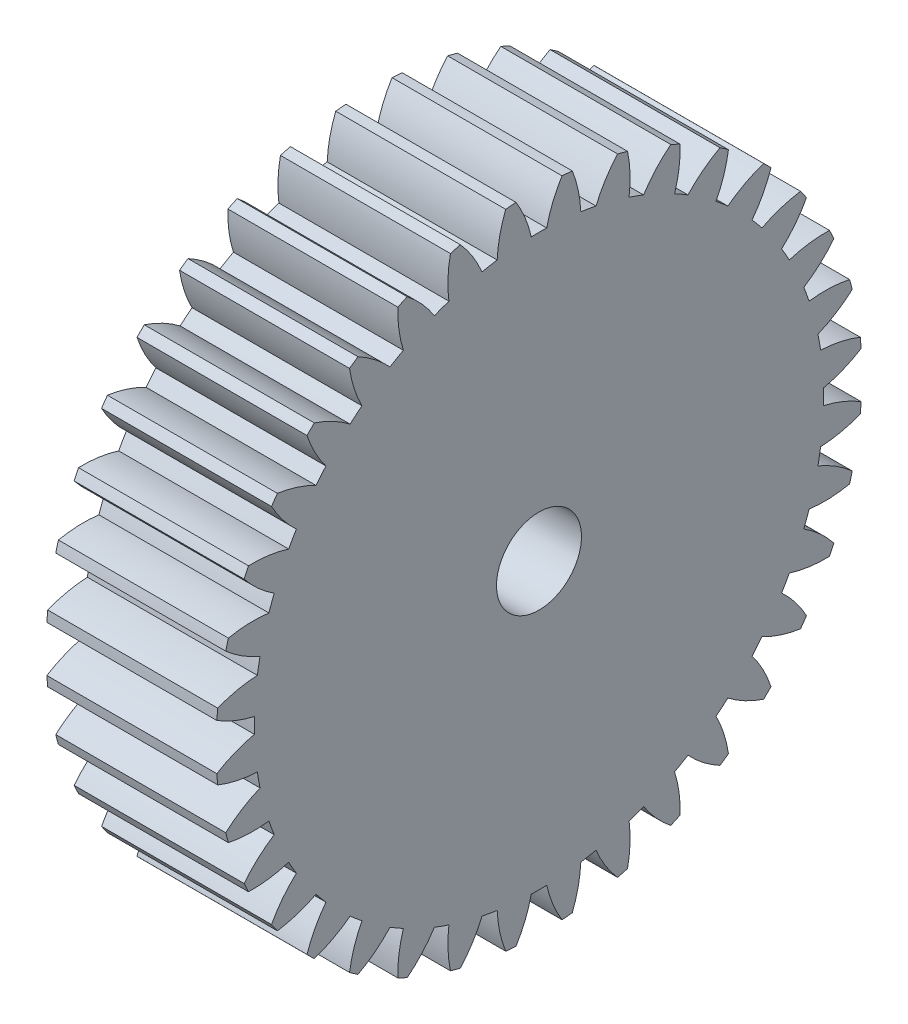
from build123d import *

# Parameters (mm, degrees)
BASPROSKE_W     = 10
BASPROSKE_H     = 19
TOOTHCUT_DEPTH  = 29.670542374
TEETHCUTS_COUNT = 36
TEETHCUTS_ANGLE = 350
BORSKE_R        = 2.5
BORE_DEPTH      = 50.0000508


with BuildPart() as part:
    # BasProSke → Base-Revolve (revolve)
    with BuildSketch(Plane(origin=(0, 0, 0), x_dir=(1, 0, 0), z_dir=(0, 1, 0)), mode=Mode.PRIVATE) as base_revolve_sk:
        with Locations((5, 9.5)):
            Rectangle(BASPROSKE_W, BASPROSKE_H)
    revolve(base_revolve_sk.sketch.rotate(Axis((-10, 0, 0), (1, 0, 0)), 180), axis=Axis((-10, 0, 0), (1, 0, 0)))

    # TooCutSke → ToothCut (cut, through all)
    with BuildSketch(Plane(origin=(0, 0, 0), x_dir=(0, 0, -1), z_dir=(1, 0, 0))):
        with BuildLine():
            ThreePointArc((0.454664826, 16.742827745), (0, 16.749), (-0.454664826, 16.742827745))
            ThreePointArc((-0.454664826, 16.742827745), (-0.817558311, 17.898033097), (-1.368909141, 18.976088452))
            ThreePointArc((-1.368909141, 18.976088452), (0, 19.0254), (1.368909141, 18.976088452))
            ThreePointArc((1.368909141, 18.976088452), (0.817558311, 17.898033097), (0.454664826, 16.742827745))
        make_face()
    toothcut = extrude(amount=TOOTHCUT_DEPTH, mode=Mode.SUBTRACT)

    # TeethCuts: ToothCut ×36 about axis
    teethcuts_axis = Axis((-10, 0, 0), (1, 0, 0))
    for i in range(1, TEETHCUTS_COUNT):
        add(toothcut.rotate(teethcuts_axis, i * TEETHCUTS_ANGLE / (TEETHCUTS_COUNT - 1)), mode=Mode.SUBTRACT)

    # BorSke → Bore (cut, symmetric)
    with BuildSketch(Plane(origin=(0, 0, 0), x_dir=(0, 0, -1), z_dir=(1, 0, 0))):
        with Locations(Location((0, 0, 0), (0, 0, 180))):
            Circle(BORSKE_R)
    extrude(amount=BORE_DEPTH, both=True, mode=Mode.SUBTRACT)


solid = part.part
